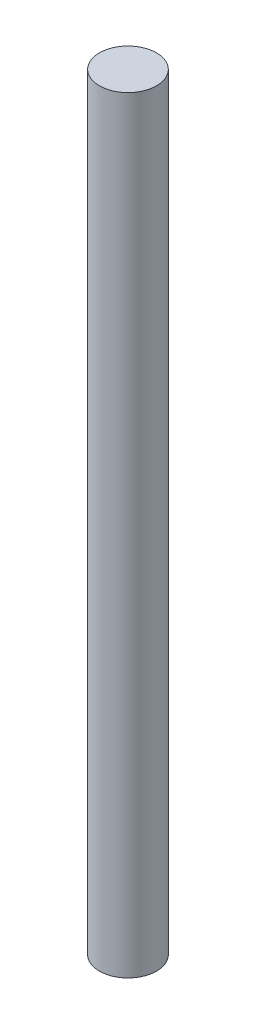
from build123d import *

# Parameters (mm, degrees)
SKETCH1_R           = 1.75
BOSS_EXTRUDE1_DEPTH = 47


with BuildPart() as part:
    # Sketch1 → Boss-Extrude1 (new body)
    with BuildSketch(Plane(origin=(0, 0, 0), x_dir=(1, 0, 0), z_dir=(0, 1, 0))):
        Circle(SKETCH1_R)
    extrude(amount=BOSS_EXTRUDE1_DEPTH)


solid = part.part
